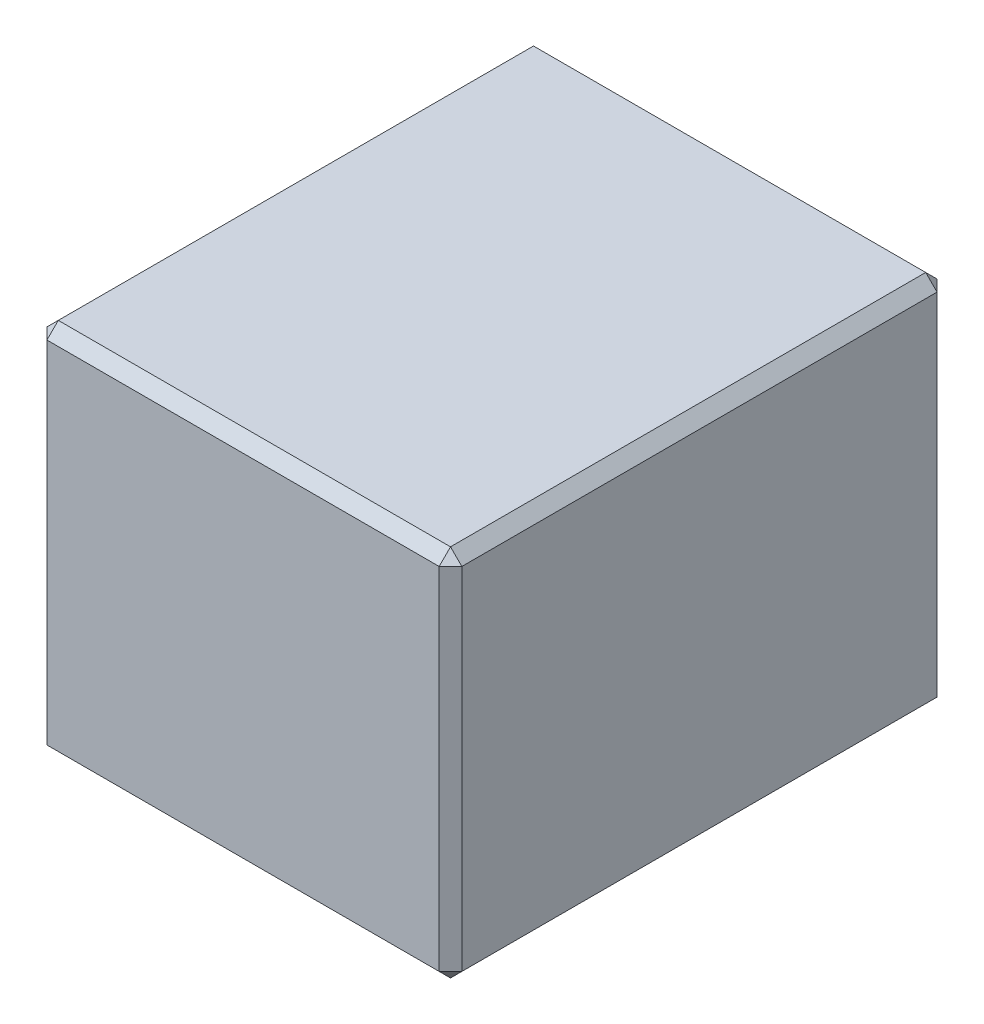
from build123d import *

# Parameters (mm, degrees)
SKETCH2_W           = 1016
SKETCH2_H           = 1219.2
BOSS_EXTRUDE1_DEPTH = 914.4
CHAMFER1_SIZE       = 27.78


with BuildPart() as part:
    # Sketch2 → Boss-Extrude1 (new body)
    with BuildSketch(Plane(origin=(0, 0, 0), x_dir=(1, 0, 0), z_dir=(0, 1, 0))):
        Rectangle(SKETCH2_W, SKETCH2_H)
    extrude(amount=BOSS_EXTRUDE1_DEPTH)

    # Chamfer1
    chamfer1_edges = [part.edges().sort_by_distance(p)[0] for p in [
        (-508, 914.4, 0),
        (0, 914.4, 609.6),
        (508, 914.4, 0),
        (0, 0, 609.6),
        (-508, 0, 0),
        (0, 0, -609.6),
        (508, 0, 0),
        (0, 914.4, -609.6),
        (508, 457.2, 609.6),
        (-508, 457.2, 609.6),
        (-508, 457.2, -609.6),
        (508, 457.2, -609.6),
    ]]
    chamfer(chamfer1_edges, length=CHAMFER1_SIZE)


solid = part.part
